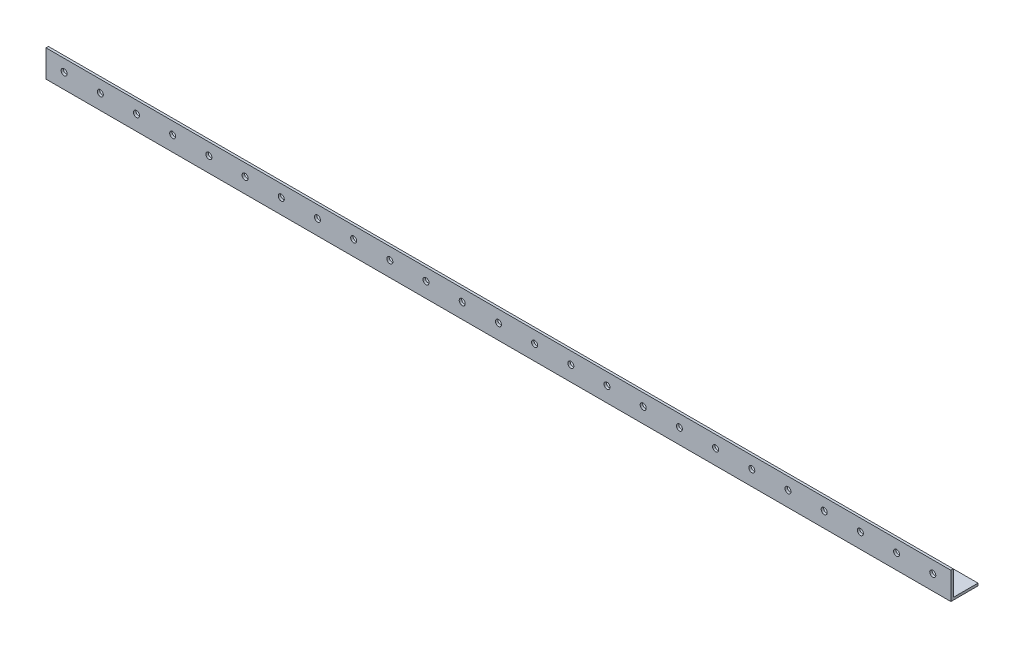
from build123d import *

# Parameters (mm, degrees)
EXTRUDE_1_DEPTH     = 1500
SKETCH_2_R          = 5
CUT_EXTRUDE_1_DEPTH = 46
SKETCH_3_R          = 5
CUT_EXTRUDE_2_DEPTH = 46


with BuildPart() as part:
    # Эскиз1 → Вытянуть-Тонкостенный1 (new body)
    with BuildSketch(Plane(origin=(0, 0, 0), x_dir=(0, 0, -1), z_dir=(1, 0, 0))):
        Polygon((45, 0), (0, 0), (0, 45), (4, 45), (4, 4), (45, 4), align=None)
    extrude(amount=EXTRUDE_1_DEPTH)

    # Эскиз2 → Вырез-Вытянуть1 (cut, through all)
    with BuildSketch(Plane.XY):
        with Locations((30, 25)):
            Circle(SKETCH_2_R)
        with Locations((90, 25)):
            Circle(SKETCH_2_R)
        with Locations((150, 25)):
            Circle(SKETCH_2_R)
        with Locations((210, 25)):
            Circle(SKETCH_2_R)
        with Locations((270, 25)):
            Circle(SKETCH_2_R)
        with Locations((330, 25)):
            Circle(SKETCH_2_R)
        with Locations((390, 25)):
            Circle(SKETCH_2_R)
        with Locations((450, 25)):
            Circle(SKETCH_2_R)
        with Locations((510, 25)):
            Circle(SKETCH_2_R)
        with Locations((570, 25)):
            Circle(SKETCH_2_R)
        with Locations((630, 25)):
            Circle(SKETCH_2_R)
        with Locations((690, 25)):
            Circle(SKETCH_2_R)
        with Locations((750, 25)):
            Circle(SKETCH_2_R)
        with Locations((810, 25)):
            Circle(SKETCH_2_R)
        with Locations((870, 25)):
            Circle(SKETCH_2_R)
        with Locations((930, 25)):
            Circle(SKETCH_2_R)
        with Locations((990, 25)):
            Circle(SKETCH_2_R)
        with Locations((1050, 25)):
            Circle(SKETCH_2_R)
        with Locations((1110, 25)):
            Circle(SKETCH_2_R)
        with Locations((1170, 25)):
            Circle(SKETCH_2_R)
        with Locations((1230, 25)):
            Circle(SKETCH_2_R)
        with Locations((1290, 25)):
            Circle(SKETCH_2_R)
        with Locations((1350, 25)):
            Circle(SKETCH_2_R)
        with Locations((1410, 25)):
            Circle(SKETCH_2_R)
        with Locations((1470, 25)):
            Circle(SKETCH_2_R)
    extrude(amount=-CUT_EXTRUDE_1_DEPTH, mode=Mode.SUBTRACT)

    # Эскиз3 → Вырез-Вытянуть2 (cut, through all)
    with BuildSketch(Plane.XZ):
        with Locations((30, -25)):
            Circle(SKETCH_3_R)
        with Locations((90, -25)):
            Circle(SKETCH_3_R)
        with Locations((150, -25)):
            Circle(SKETCH_3_R)
        with Locations((210, -25)):
            Circle(SKETCH_3_R)
        with Locations((270, -25)):
            Circle(SKETCH_3_R)
        with Locations((330, -25)):
            Circle(SKETCH_3_R)
        with Locations((390, -25)):
            Circle(SKETCH_3_R)
        with Locations((450, -25)):
            Circle(SKETCH_3_R)
        with Locations((510, -25)):
            Circle(SKETCH_3_R)
        with Locations((570, -25)):
            Circle(SKETCH_3_R)
        with Locations((630, -25)):
            Circle(SKETCH_3_R)
        with Locations((690, -25)):
            Circle(SKETCH_3_R)
        with Locations((750, -25)):
            Circle(SKETCH_3_R)
        with Locations((810, -25)):
            Circle(SKETCH_3_R)
        with Locations((870, -25)):
            Circle(SKETCH_3_R)
        with Locations((930, -25)):
            Circle(SKETCH_3_R)
        with Locations((990, -25)):
            Circle(SKETCH_3_R)
        with Locations((1050, -25)):
            Circle(SKETCH_3_R)
        with Locations((1110, -25)):
            Circle(SKETCH_3_R)
        with Locations((1170, -25)):
            Circle(SKETCH_3_R)
        with Locations((1230, -25)):
            Circle(SKETCH_3_R)
        with Locations((1290, -25)):
            Circle(SKETCH_3_R)
        with Locations((1350, -25)):
            Circle(SKETCH_3_R)
        with Locations((1410, -25)):
            Circle(SKETCH_3_R)
        with Locations((1470, -25)):
            Circle(SKETCH_3_R)
    extrude(amount=-CUT_EXTRUDE_2_DEPTH, mode=Mode.SUBTRACT)


solid = part.part
